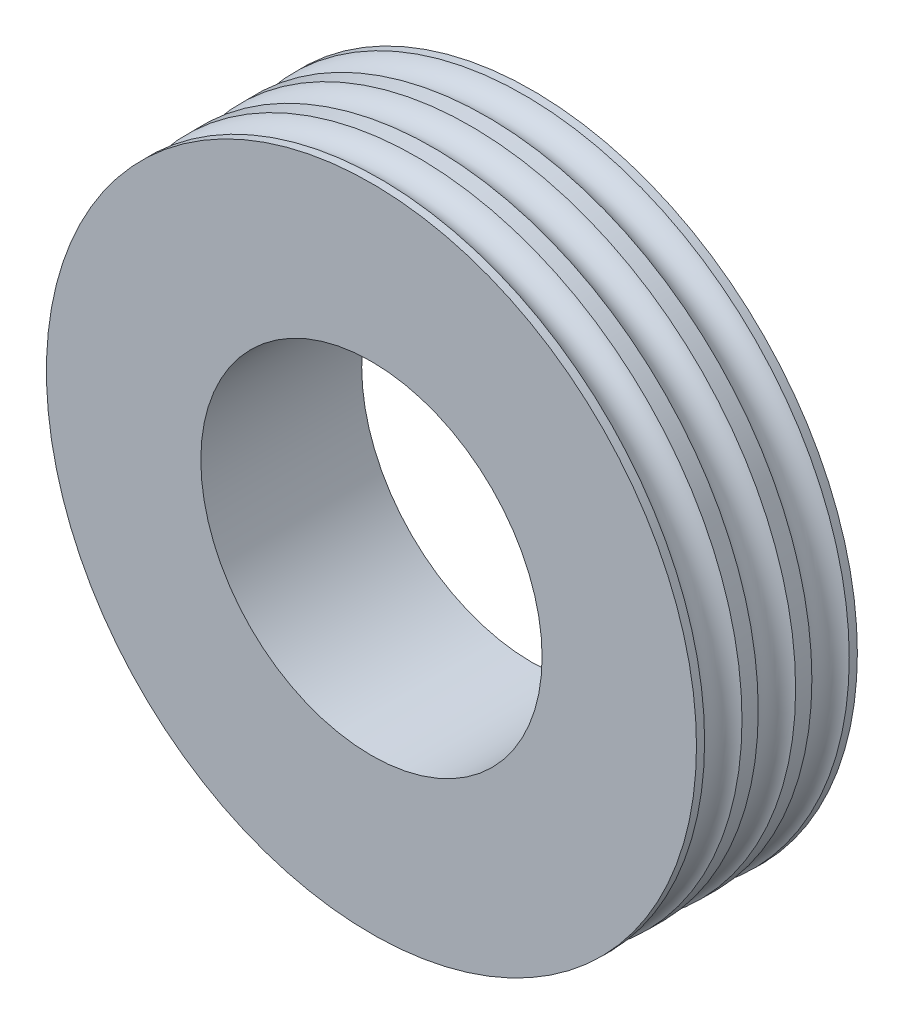
from build123d import *


with BuildPart() as part:
    # Sketch2 → Revolve1 (revolve)
    with BuildSketch(Plane(origin=(0, 0, 0), x_dir=(0, 0, -1), z_dir=(1, 0, 0))):
        with BuildLine():
            Line((-0.34, 2.1), (-0.34, 4))
            Line((-0.34, 4), (-0.44, 4))
            ThreePointArc((-0.44, 4), (-0.67, 3.849201276), (-0.9, 4))
            Line((-0.9, 4), (-1, 4))
            Line((-1, 4), (-1, 2.1))
            Line((-1, 2.1), (-0.34, 2.1))
        make_face()
    revolve1 = revolve(axis=Axis((0, 0, 3.014677367), (0, 0, -1)))

    # Mirror2: Revolve1 across plane
    add(revolve1.mirror(Plane(origin=(0, 0, 0.34), x_dir=(1, 0, 0), z_dir=(0, 0, -1))))

    # Mirror3: Revolve1 across plane
    add(revolve1.mirror(Plane.XY.offset(1)))


solid = part.part
